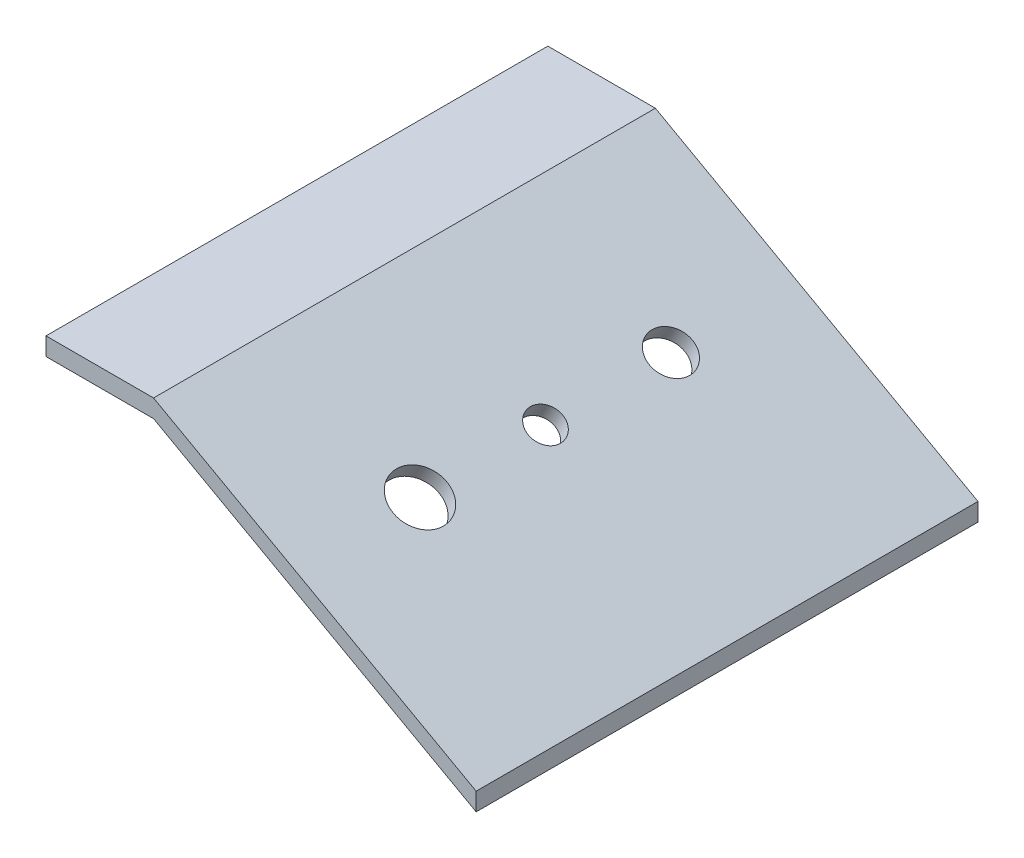
from build123d import *

# Parameters (mm, degrees)
BOSS_EXTRUDE1_DEPTH = 152.4
SKETCH2_R           = 9.525
SKETCH2_R_2         = 6.096
SKETCH2_R_3         = 7.62
CUT_EXTRUDE1_DEPTH  = 152.4
SKETCH3_R           = 3.175
BOSS_EXTRUDE2_DEPTH = 12.7
SKETCH4_R           = 3.175
BOSS_EXTRUDE3_DEPTH = 12.7
BOSS_EXTRUDE5_DEPTH = 12.7
BOSS_EXTRUDE6_DEPTH = 12.7


with BuildPart() as part:
    # Sketch1 → Boss-Extrude1 (new body)
    with BuildSketch(Plane.XY):
        Polygon((0, 0), (38.1, 0), (152.4, -63.5), (152.4, -57.15), (38.1, 6.35), (0, 6.35), align=None)
    extrude(amount=BOSS_EXTRUDE1_DEPTH)

    # Sketch2 → Cut-Extrude1 (cut)
    with BuildSketch(Plane(origin=(11.681603774, 21.026886792, 0), x_dir=(0.874157276, -0.485642931, 0), z_dir=(0.485642931, 0.874157276, 0))):
        with Locations((87.371559607, -120.65)):
            Circle(SKETCH2_R)
        with Locations((87.371559607, -76.2)):
            Circle(SKETCH2_R_2)
        with Locations((87.371559607, -31.75)):
            Circle(SKETCH2_R_3)
    extrude(amount=-CUT_EXTRUDE1_DEPTH, mode=Mode.SUBTRACT)

    # Sketch3 → Boss-Extrude2 (add)
    with BuildSketch(Plane.XZ):
        with Locations((12.7, 6.35)):
            Circle(SKETCH3_R)
        with Locations((12.7, 146.05)):
            Circle(SKETCH3_R)
    extrude(amount=BOSS_EXTRUDE2_DEPTH)

    # Sketch4 → Boss-Extrude3 (add)
    with BuildSketch(Plane(origin=(8.985849057, 16.174528302, 0), x_dir=(0.874157276, -0.485642931, 0), z_dir=(-0.485642931, -0.874157276, 0))):
        with Locations((151.359895011, 6.35)):
            Circle(SKETCH4_R)
        with Locations((151.359895011, 146.05)):
            Circle(SKETCH4_R)
    extrude(amount=BOSS_EXTRUDE3_DEPTH)

    # Sketch7 → Boss-Extrude5 (add)
    with BuildSketch(Plane.XY.offset(152.4)):
        Polygon((0, 0), (0, 6.35), (38.1, 6.35), (152.4, -57.15), (152.4, -63.5), (38.1, 0), align=None)
    extrude(amount=BOSS_EXTRUDE5_DEPTH)

    # Sketch8 → Boss-Extrude6 (add)
    with BuildSketch(Plane(origin=(0, 0, 0), x_dir=(-1, 0, 0), z_dir=(0, 0, -1))):
        Polygon((0, 0), (-38.1, 0), (-152.4, -63.5), (-152.4, -57.15), (-38.1, 6.35), (0, 6.35), align=None)
    extrude(amount=BOSS_EXTRUDE6_DEPTH)


solid = part.part
